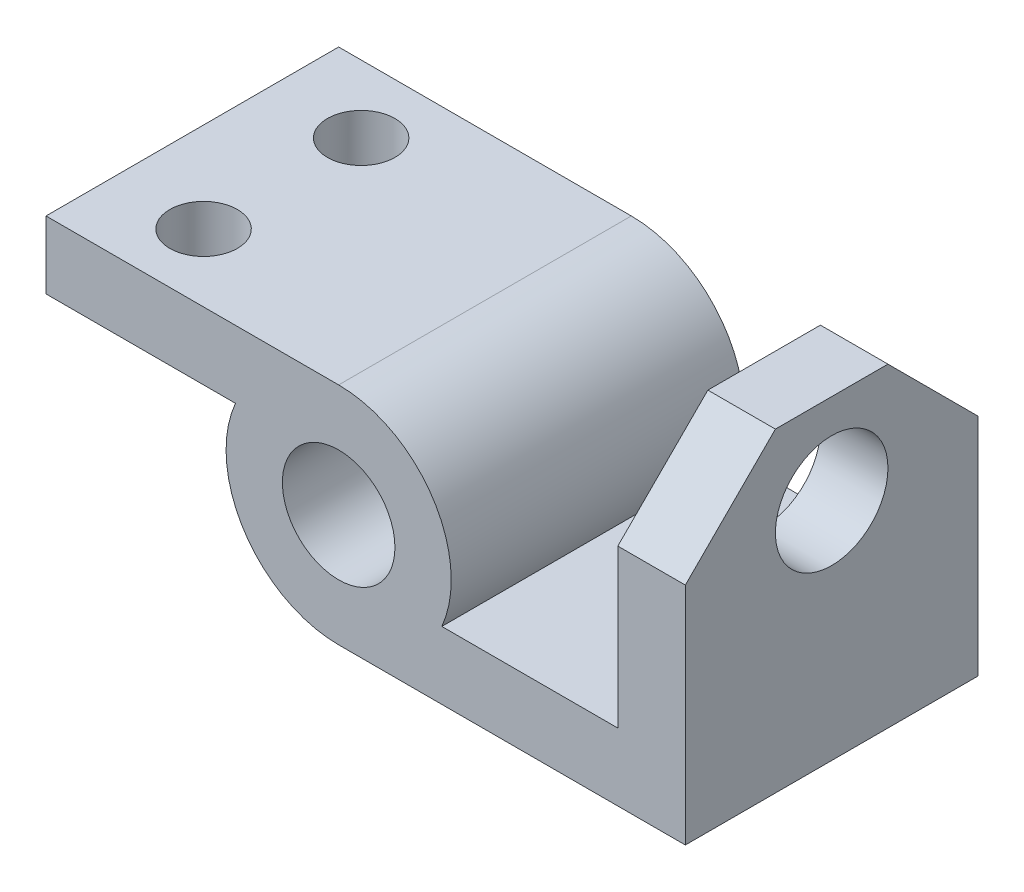
from build123d import *

# Parameters (mm, degrees)
SKETCH1_R                = 31.75
BOSS_EXTRUDE1_DEPTH      = 82.55
SKETCH4_W                = 82.55
SKETCH4_H                = 19.05
BOSS_EXTRUDE2_DEPTH      = 46.99
BOSS_EXTRUDE2_DEPTH_BACK = 31.75
SKETCH5_W                = 82.55
SKETCH5_H                = 88.9
SKETCH5_R                = 15.875
BOSS_EXTRUDE3_DEPTH      = 19.05
CHAMFER1_SIZE            = 25.4
SKETCH8_W                = 82.55
SKETCH8_H                = 19.05
BOSS_EXTRUDE4_DEPTH      = 31.75
BOSS_EXTRUDE4_DEPTH_BACK = 50.8
SKETCH3_R                = 15.875
CUT_EXTRUDE2_DEPTH       = 163.576
SKETCH9_R                = 9.525
CUT_EXTRUDE3_DEPTH       = 163.576


with BuildPart() as part:
    # Sketch1 → Boss-Extrude1 (new body)
    with BuildSketch(Plane.XY):
        Circle(SKETCH1_R)
    extrude(amount=-BOSS_EXTRUDE1_DEPTH)

    # Sketch4 → Boss-Extrude2 (add, two sides)
    with BuildSketch(Plane(origin=(31.75, 0, 0), x_dir=(0, 0, -1), z_dir=(1, 0, 0))) as boss_extrude2_sk:
        with Locations((41.275, -22.225)):
            Rectangle(SKETCH4_W, SKETCH4_H)
    extrude(amount=BOSS_EXTRUDE2_DEPTH)
    extrude(boss_extrude2_sk.sketch, amount=-BOSS_EXTRUDE2_DEPTH_BACK)

    # Sketch5 → Boss-Extrude3 (add)
    with BuildSketch(Plane(origin=(78.74, 0, 0), x_dir=(0, 0, -1), z_dir=(1, 0, 0))):
        with Locations((41.275, 12.7)):
            Rectangle(SKETCH5_W, SKETCH5_H)
        with Locations((41.275, 31.75)):
            Circle(SKETCH5_R, mode=Mode.SUBTRACT)
    extrude(amount=BOSS_EXTRUDE3_DEPTH)

    # Chamfer1
    chamfer1_edges = [part.edges().sort_by_distance(p)[0] for p in [
        (88.265, 57.15, -82.55),
        (88.265, 57.15, 0),
    ]]
    chamfer(chamfer1_edges, length=CHAMFER1_SIZE)

    # Sketch8 → Boss-Extrude4 (add, two sides)
    with BuildSketch(Plane(origin=(-31.75, 0, 0), x_dir=(0, 0, -1), z_dir=(1, 0, 0))) as boss_extrude4_sk:
        with Locations((41.275, 22.225)):
            Rectangle(SKETCH8_W, SKETCH8_H)
    extrude(amount=BOSS_EXTRUDE4_DEPTH)
    extrude(boss_extrude4_sk.sketch, amount=-BOSS_EXTRUDE4_DEPTH_BACK)

    # Sketch3 → Cut-Extrude2 (cut)
    with BuildSketch(Plane.XY):
        Circle(SKETCH3_R)
    extrude(amount=-CUT_EXTRUDE2_DEPTH, mode=Mode.SUBTRACT)

    # Sketch9 → Cut-Extrude3 (cut)
    with BuildSketch(Plane(origin=(0, 31.75, 0), x_dir=(1, 0, 0), z_dir=(0, 1, 0))):
        with Locations((-57.15, 63.5)):
            Circle(SKETCH9_R)
        with Locations((-57.15, 19.05)):
            Circle(SKETCH9_R)
    extrude(amount=-CUT_EXTRUDE3_DEPTH, mode=Mode.SUBTRACT)


solid = part.part
